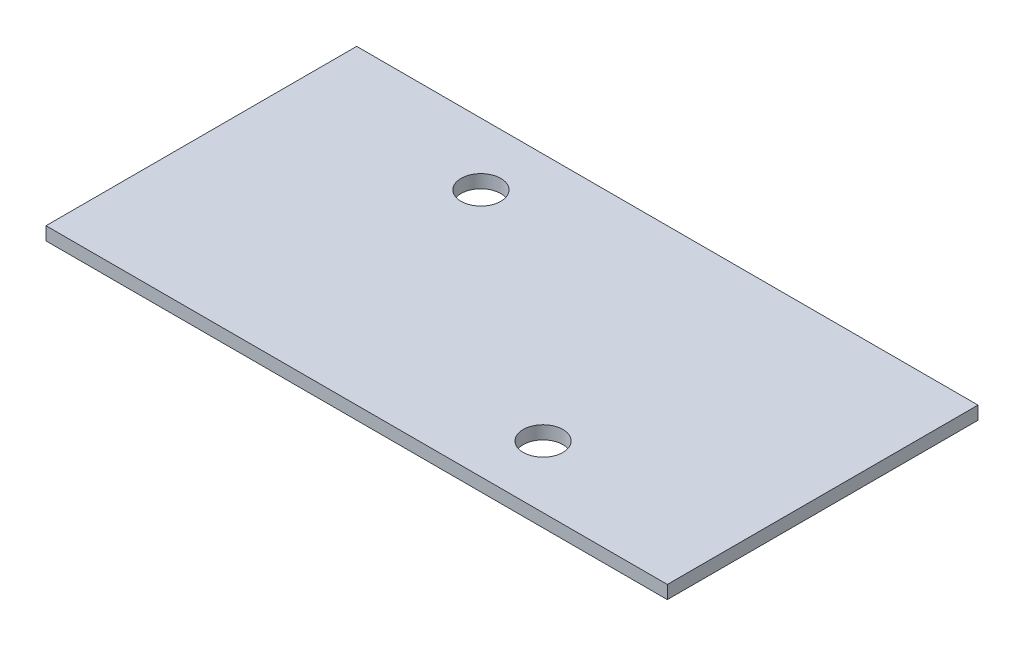
from build123d import *

# Parameters (mm, degrees)
SKETCH1_W           = 50
SKETCH1_H           = 25
BOSS_EXTRUDE1_DEPTH = 1.06
SKETCH2_R           = 1.6
CUT_EXTRUDE1_DEPTH  = 2.06


with BuildPart() as part:
    # Sketch1 → Boss-Extrude1 (new body)
    with BuildSketch(Plane(origin=(0, 0, 0), x_dir=(1, 0, 0), z_dir=(0, 1, 0))):
        Rectangle(SKETCH1_W, SKETCH1_H)
    extrude(amount=BOSS_EXTRUDE1_DEPTH)

    # Sketch2 → Cut-Extrude1 (cut, through all)
    with BuildSketch(Plane(origin=(0, 1.06, 0), x_dir=(1, 0, 0), z_dir=(0, 1, 0))):
        with Locations((-10, 7.5)):
            Circle(SKETCH2_R)
        with Locations((10, -7.5)):
            Circle(SKETCH2_R)
    extrude(amount=-CUT_EXTRUDE1_DEPTH, mode=Mode.SUBTRACT)


solid = part.part
